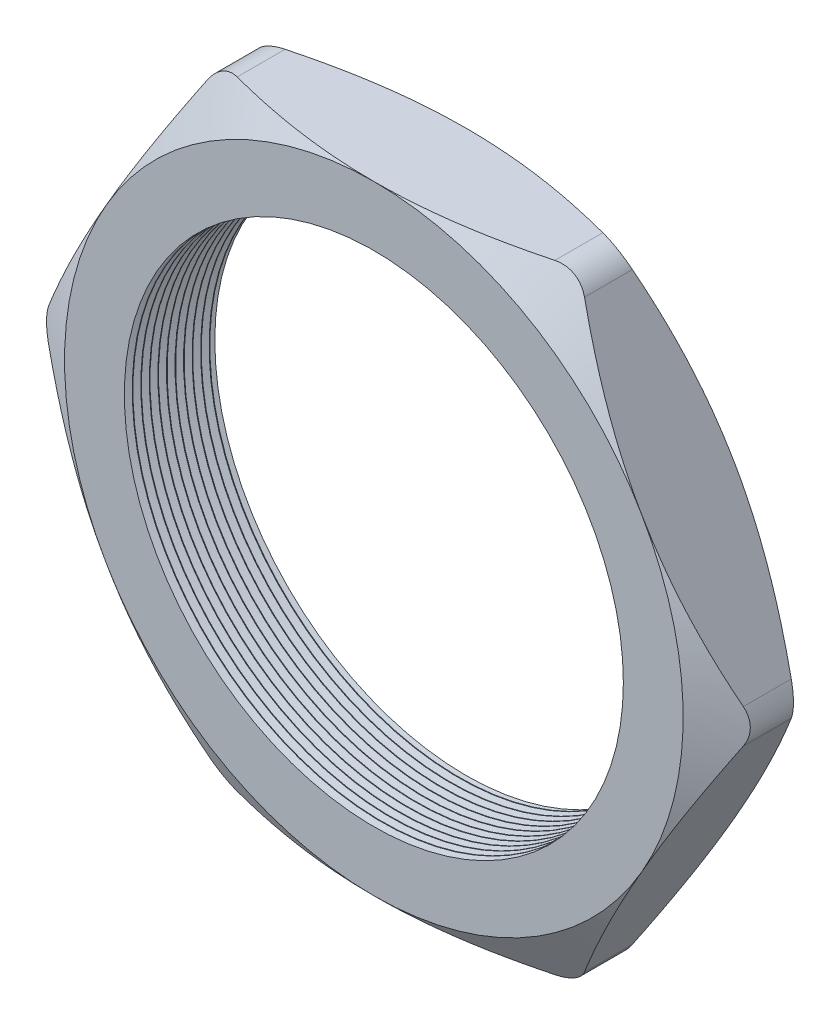
from build123d import *

# Parameters (mm, degrees)
SKETCH1_R          = 18.542
EXTRUDE1_DEPTH     = 6.858
SKETCH2_OUTSIDE_W  = 96.42
SKETCH2_OUTSIDE_H  = 89.308
SKETCH2_OUTSIDE_R  = 22.987
CUT_EXTRUDE1_DEPTH = 7.858
CUT_EXTRUDE1_DRAFT = -60
SKETCH3_OUTSIDE_W  = 96.42
SKETCH3_OUTSIDE_H  = 89.308
SKETCH3_OUTSIDE_R  = 22.987
CUT_EXTRUDE2_DEPTH = 7.858
CUT_EXTRUDE2_DRAFT = -60
FILLET1_R          = 2.54
LPATTERN1_COUNT    = 11
LPATTERN1_PITCH    = 0.635


with BuildPart() as part:
    # Sketch1 → Extrude1 (new body)
    with BuildSketch(Plane.XY):
        Polygon((-26.543101276, 0), (-13.271550638, -22.987), (13.271550638, -22.987), (26.543101276, 0), (13.271550638, 22.987), (-13.271550638, 22.987), align=None)
        Circle(SKETCH1_R, mode=Mode.SUBTRACT)
    extrude(amount=EXTRUDE1_DEPTH)


with BuildPart() as cut_extrude1_tool:
    # Sketch2 outside → Cut-Extrude1 (with draft: the straight prism first)
    with BuildSketch(Plane.XY.offset(6.858)):
        Rectangle(SKETCH2_OUTSIDE_W, SKETCH2_OUTSIDE_H)
        Circle(SKETCH2_OUTSIDE_R, mode=Mode.SUBTRACT)
    extrude(amount=-CUT_EXTRUDE1_DEPTH)
    # Cut-Extrude1: the draft: its side faces are tilted about the plane it starts from
    cut_extrude1_sides = [cut_extrude1_tool.faces().sort_by_distance(p)[0] for p in [
        (0, -44.654, 2.929),
        (48.21, 0, 2.929),
        (0, 44.654, 2.929),
        (-48.21, 0, 2.929),
        (-22.987, 0, 2.929),
    ]]
    draft(cut_extrude1_sides, Plane.XY.offset(6.858), CUT_EXTRUDE1_DRAFT)


with BuildPart() as part_1:
    add(part.part)

    # Cut-Extrude1: cut by cut_extrude1_tool
    add(cut_extrude1_tool.part, mode=Mode.SUBTRACT)


with BuildPart() as cut_extrude2_tool:
    # Sketch3 outside → Cut-Extrude2 (with draft: the straight prism first)
    with BuildSketch(Plane(origin=(0, 0, 0), x_dir=(-1, 0, 0), z_dir=(0, 0, -1))):
        Rectangle(SKETCH3_OUTSIDE_W, SKETCH3_OUTSIDE_H)
        Circle(SKETCH3_OUTSIDE_R, mode=Mode.SUBTRACT)
    extrude(amount=-CUT_EXTRUDE2_DEPTH)
    # Cut-Extrude2: the draft: its side faces are tilted about the plane it starts from
    cut_extrude2_sides = [cut_extrude2_tool.faces().sort_by_distance(p)[0] for p in [
        (0, -44.654, 3.929),
        (-48.21, 0, 3.929),
        (0, 44.654, 3.929),
        (48.21, 0, 3.929),
        (22.987, 0, 3.929),
    ]]
    draft(cut_extrude2_sides, Plane(origin=(0, 0, 0), x_dir=(-1, 0, 0), z_dir=(0, 0, -1)), CUT_EXTRUDE2_DRAFT)


with BuildPart() as part_2:
    add(part_1.part)

    # Cut-Extrude2: cut by cut_extrude2_tool
    add(cut_extrude2_tool.part, mode=Mode.SUBTRACT)

    # Fillet1
    fillet1_edges = [part_2.edges().sort_by_distance(p)[0] for p in [
        (26.543101276, 0, 3.429),
        (13.271550638, -22.987, 3.429),
        (-13.271550638, -22.987, 3.429),
        (-26.543101276, 0, 3.429),
        (-13.271550638, 22.987, 3.429),
        (13.271550638, 22.987, 3.429),
    ]]
    fillet(fillet1_edges, radius=FILLET1_R)

    # Sketch4 → Cut-Revolve1 (revolve, cut)
    with BuildSketch(Plane(origin=(0, 0, 0), x_dir=(1, 0, 0), z_dir=(0, 1, 0)), mode=Mode.PRIVATE) as cut_revolve1_sk:
        Polygon((-18.542, -6.858), (-18.542, -6.271412127), (-19.05, -6.564706063), align=None)
    cut_revolve1 = revolve(cut_revolve1_sk.sketch.rotate(Axis((0, 0, 0), (0, 0, 1)), 180), axis=Axis((0, 0, 0), (0, 0, 1)), mode=Mode.SUBTRACT)  # turned: the seam where the file's is

    # LPattern1: Cut-Revolve1 ×11
    with Locations(*[(0, 0, -i * LPATTERN1_PITCH) for i in range(1, LPATTERN1_COUNT)]):
        add(cut_revolve1, mode=Mode.SUBTRACT)


solid = part_2.part
